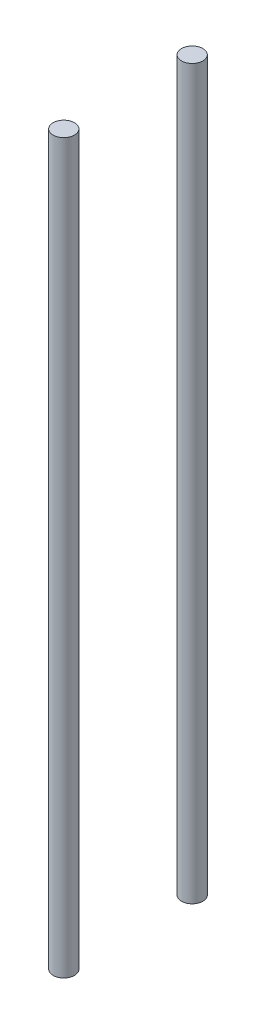
from build123d import *

# Parameters (mm, degrees)
SKETCH3_R        = 0.25
EXTRUDE1_DEPTH   = 17
EXTRUDE1_2_DEPTH = 17


with BuildPart() as part:
    # Sketch3 → Extrude1 (new body)
    with BuildSketch(Plane(origin=(0, 0, 0), x_dir=(-1, 0, 0), z_dir=(0, 1, 0))):
        with Locations((0, 1.5)):
            Circle(SKETCH3_R)
    extrude(amount=EXTRUDE1_DEPTH)


with BuildPart() as body_2:
    # Sketch3 → Extrude1 2 (new body)
    with BuildSketch(Plane(origin=(0, 0, 0), x_dir=(-1, 0, 0), z_dir=(0, 1, 0))):
        with Locations((0, -1.5)):
            Circle(SKETCH3_R)
    extrude(amount=EXTRUDE1_2_DEPTH)


solid = Compound([part.part, body_2.part])
